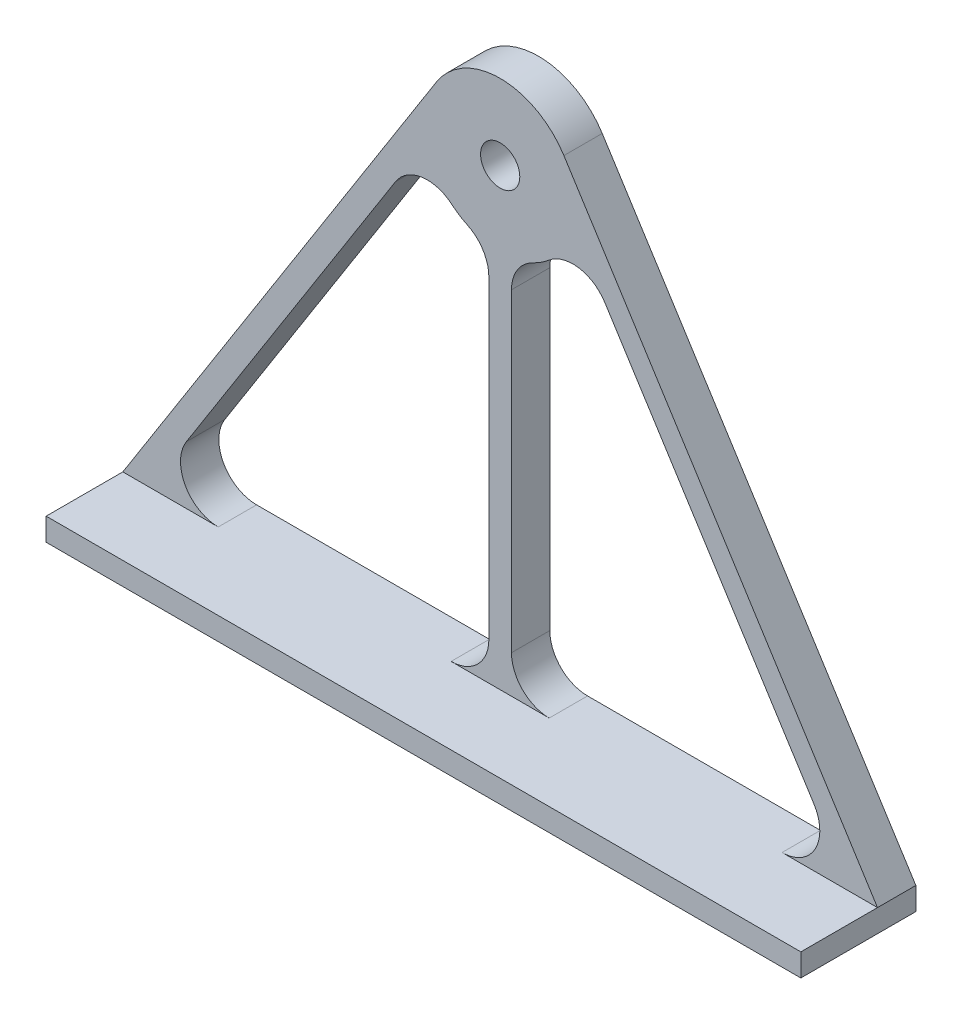
from build123d import *

# Parameters (mm, degrees)
SKETCH2_R           = 2.6
BOSS_EXTRUDE1_DEPTH = 5.08
SKETCH3_W           = 100
SKETCH3_H           = 3
BOSS_EXTRUDE2_DEPTH = 10.16


with BuildPart() as part:
    # Sketch2 → Boss-Extrude1 (new body)
    with BuildSketch(Plane.XY):
        with BuildLine():
            Line((-50, -3), (50, -3))
            Line((50, -3), (50, 0))
            Line((50, 0), (8.444744964, 65.520221164))
            ThreePointArc((8.444744964, 65.520221164), (0, 70.1642635), (-8.444744964, 65.520221164))
            Line((-8.444744964, 65.520221164), (-50, 0))
            Line((-50, 0), (-50, -3))
        make_face()
        with Locations((0, 60.1642635)):
            Circle(SKETCH2_R, mode=Mode.SUBTRACT)
        with BuildLine():
            Line((-13.873524959, 51.359417946), (-41.57784754, 7.677978832))
            ThreePointArc((-41.57784754, 7.677978832), (-41.736678897, 2.590632257), (-37.355475058, 0))
            Line((-37.355475058, 0), (-6.5, 0))
            ThreePointArc((-6.5, 0), (-2.964466094, 1.464466094), (-1.5, 5))
            Line((-1.5, 5), (-1.5, 46.645757665))
            ThreePointArc((-1.5, 46.645757665), (-2.267191634, 49.307210903), (-4.333333333, 51.151926277))
            ThreePointArc((-4.333333333, 51.151926277), (-5.426311672, 51.764552693), (-6.434101651, 52.509047243))
            ThreePointArc((-6.434101651, 52.509047243), (-10.41474909, 53.62278713), (-13.873524959, 51.359417946))
        make_face(mode=Mode.SUBTRACT)
        with BuildLine():
            Line((13.873524959, 51.359417946), (41.57784754, 7.677978832))
            ThreePointArc((41.57784754, 7.677978832), (41.736678897, 2.590632257), (37.355475058, 0))
            Line((37.355475058, 0), (6.5, 0))
            ThreePointArc((6.5, 0), (2.964466094, 1.464466094), (1.5, 5))
            Line((1.5, 5), (1.5, 46.645757665))
            ThreePointArc((1.5, 46.645757665), (2.267191634, 49.307210903), (4.333333333, 51.151926277))
            ThreePointArc((4.333333333, 51.151926277), (5.426311672, 51.764552693), (6.434101651, 52.509047243))
            ThreePointArc((6.434101651, 52.509047243), (10.41474909, 53.62278713), (13.873524959, 51.359417946))
        make_face(mode=Mode.SUBTRACT)
    extrude(amount=BOSS_EXTRUDE1_DEPTH)

    # Sketch3 → Boss-Extrude2 (add)
    with BuildSketch(Plane.XY.offset(5.08)):
        with Locations((0, -1.5)):
            Rectangle(SKETCH3_W, SKETCH3_H)
    extrude(amount=BOSS_EXTRUDE2_DEPTH)


solid = part.part
